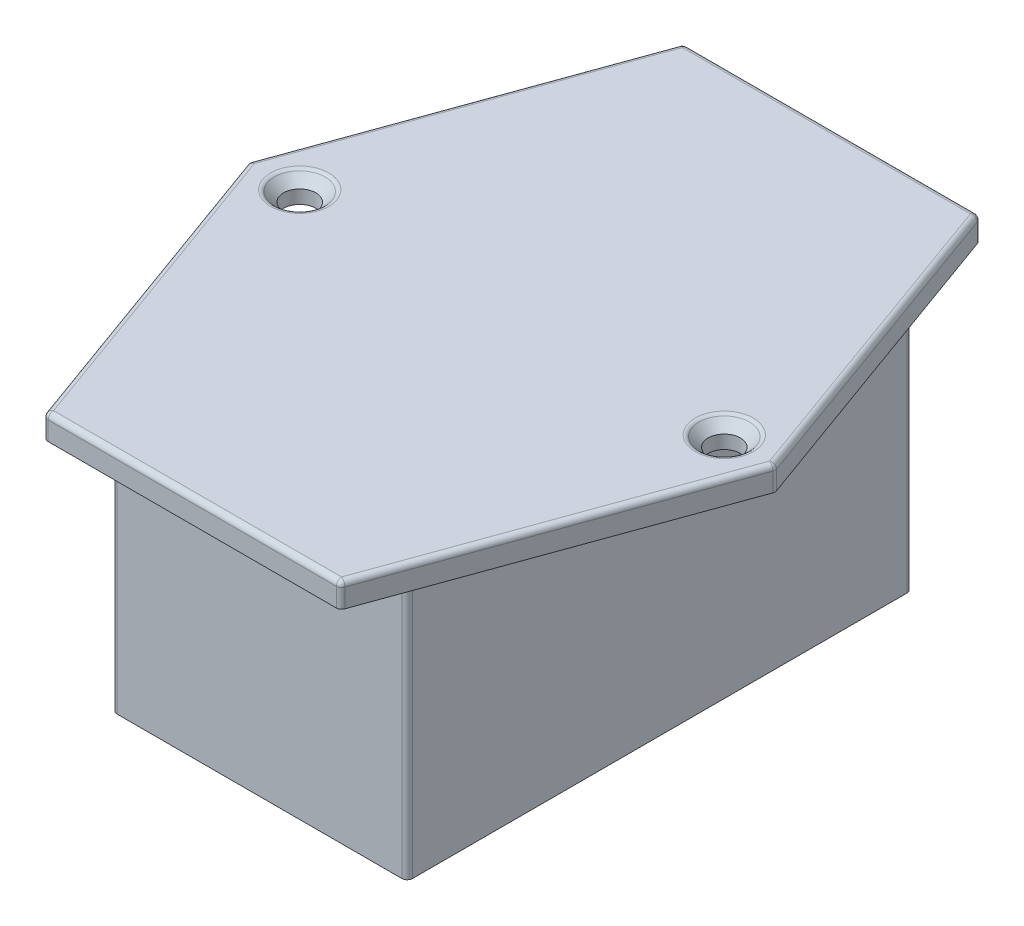
from build123d import *

# Parameters (mm, degrees)
SKETCH1_W           = 27.5
SKETCH1_H           = 47
BOSS_EXTRUDE1_DEPTH = 25
SKETCH2_R           = 1.5
BOSS_EXTRUDE2_DEPTH = 2.25
CHAMFER1_SIZE       = 1
FILLET1_R           = 0.5


with BuildPart() as part:
    # Sketch1 → Boss-Extrude1 (new body)
    with BuildSketch(Plane(origin=(0, 0, 0), x_dir=(1, 0, 0), z_dir=(0, 1, 0))):
        with Locations((13.75, 23.5)):
            Rectangle(SKETCH1_W, SKETCH1_H)
    extrude(amount=BOSS_EXTRUDE1_DEPTH)

    # Sketch2 → Boss-Extrude2 (add)
    with BuildSketch(Plane(origin=(0, 25, 0), x_dir=(1, 0, 0), z_dir=(0, 1, 0))):
        Polygon((0, 53.25), (27.5, 53.25), (38.25, 23.5), (27.5, -6.25), (0, -6.25), (-10.75, 23.5), align=None)
        with Locations((-6, 23.5)):
            Circle(SKETCH2_R, mode=Mode.SUBTRACT)
        with Locations((33.5, 23.5)):
            Circle(SKETCH2_R, mode=Mode.SUBTRACT)
    extrude(amount=BOSS_EXTRUDE2_DEPTH)

    # Chamfer1
    chamfer1_edges = [part.edges().sort_by_distance(p)[0] for p in [
        (-7.5, 27.25, -23.5),
        (32, 27.25, -23.5),
    ]]
    chamfer(chamfer1_edges, length=CHAMFER1_SIZE)

    # Fillet1
    fillet1_edges = [part.edges().sort_by_distance(p)[0] for p in [
        (-5.375, 27.25, -38.375),
        (-5.375, 27.25, -8.625),
        (13.75, 27.25, 6.25),
        (32.875, 27.25, -8.625),
        (32.875, 27.25, -38.375),
        (13.75, 27.25, -53.25),
        (0, 26.125, -53.25),
        (-10.75, 26.125, -23.5),
        (0, 26.125, 6.25),
        (27.5, 26.125, 6.25),
        (38.25, 26.125, -23.5),
        (27.5, 26.125, -53.25),
        (31, 27.25, -23.5),
        (-8.5, 27.25, -23.5),
        (0, 12.5, -47),
        (27.5, 12.5, -47),
        (27.5, 12.5, 0),
        (0, 12.5, 0),
    ]]
    fillet(fillet1_edges, radius=FILLET1_R)


solid = part.part
